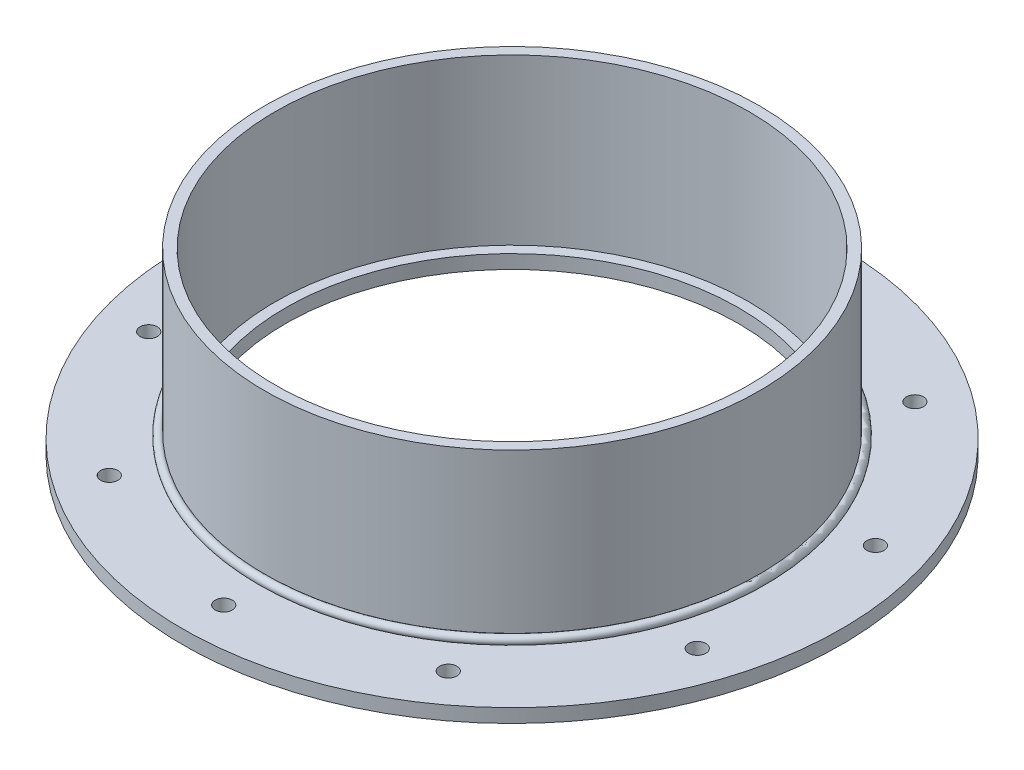
from build123d import *

# Parameters (mm, degrees)
SKETCH1_W          = 47.625
SKETCH1_H          = 6.35
SKETCH2_W          = 4.7625
SKETCH2_H          = 76.2
SKETCH4_R          = 3.96875
CUT_EXTRUDE1_DEPTH = 7.35
CIRPATTERN1_COUNT  = 10


with BuildPart() as part:
    # Sketch1 → Revolve1 (revolve)
    with BuildSketch(Plane.XY, mode=Mode.PRIVATE) as revolve1_sk:
        with Locations((-128.5875, 3.175)):
            Rectangle(SKETCH1_W, SKETCH1_H)
    revolve(revolve1_sk.sketch.rotate(Axis((0, 0, 0), (0, 1, 0)), 270), axis=Axis((0, 0, 0), (0, 1, 0)))  # turned: the seam where the file's is

    # Sketch4 → Cut-Extrude1 (cut, through all)
    with BuildSketch(Plane(origin=(0, 6.35, 0), x_dir=(1, 0, 0), z_dir=(0, 1, 0))):
        with Locations(Location((0, 133.35, 0), (0, 0, 270))):  # turned: the seam where the file's is
            Circle(SKETCH4_R)
    cut_extrude1 = extrude(amount=-CUT_EXTRUDE1_DEPTH, mode=Mode.SUBTRACT)

    # CirPattern1: Cut-Extrude1 ×10 about axis
    cirpattern1_axis = Axis((0, 0, 0), (0, 1, 0))
    for i in range(1, CIRPATTERN1_COUNT):
        add(cut_extrude1.rotate(cirpattern1_axis, i * 360 / CIRPATTERN1_COUNT), mode=Mode.SUBTRACT)


with BuildPart() as body_2:
    # Sketch2 → Revolve2 (revolve)
    with BuildSketch(Plane.XY, mode=Mode.PRIVATE) as revolve2_sk:
        with Locations((-111.91875, 44.45)):
            Rectangle(SKETCH2_W, SKETCH2_H)
    revolve(revolve2_sk.sketch.rotate(Axis((0, 0, 0), (0, 1, 0)), 270), axis=Axis((0, 0, 0), (0, 1, 0)))  # turned: the seam where the file's is


with BuildPart() as body_3:
    # Sketch3 → Revolve3 (revolve)
    with BuildSketch(Plane.XY, mode=Mode.PRIVATE) as revolve3_sk:
        with BuildLine():
            Line((-114.3, 6.35), (-117.085775819, 6.35))
            ThreePointArc((-117.085775819, 6.35), (-116.926537909, 8.976537909), (-114.3, 9.135775819))
            Line((-114.3, 9.135775819), (-114.3, 6.35))
        make_face()
    revolve(revolve3_sk.sketch.rotate(Axis((0, 0, 0), (0, 1, 0)), 270), axis=Axis((0, 0, 0), (0, 1, 0)))  # turned: the seam where the file's is


solid = Compound([part.part, body_2.part, body_3.part])
